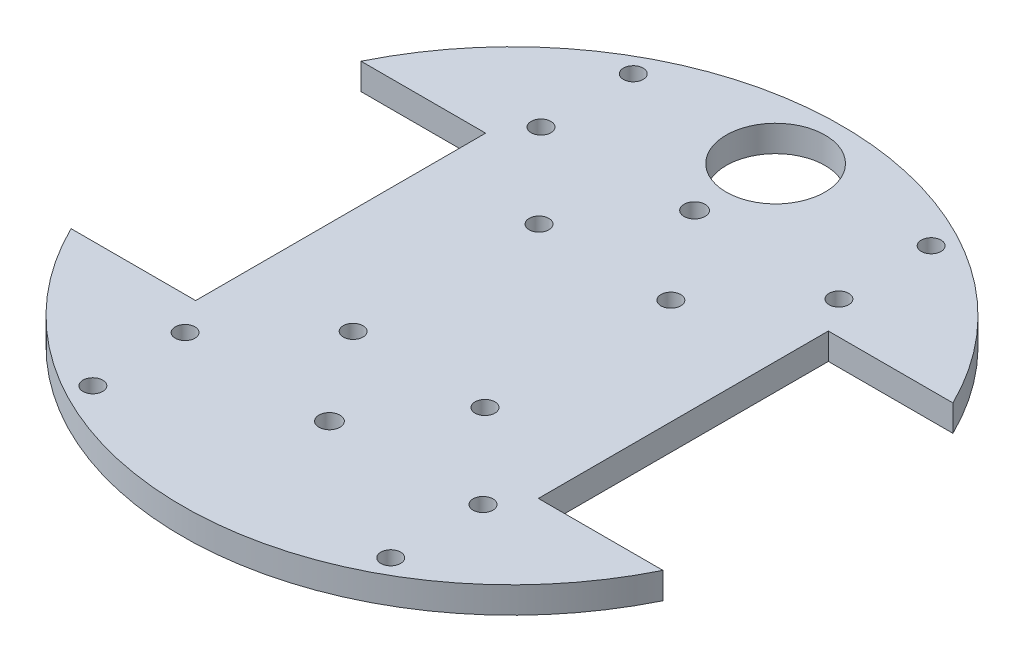
from build123d import *

# Parameters (mm, degrees)
SKETCH1_R           = 1.5
SKETCH1_R_2         = 1.6
SKETCH1_R_3         = 7.5
BOSS_EXTRUDE1_DEPTH = 4


with BuildPart() as part:
    # Sketch1 → Boss-Extrude1 (new body)
    with BuildSketch(Plane(origin=(0, 0, 0), x_dir=(1, 0, 0), z_dir=(0, 1, 0))):
        with BuildLine():
            Line((-44.899888641, 22), (-26, 22))
            Line((-26, 22), (-26, -22))
            Line((-26, -22), (-44.899888641, -22))
            ThreePointArc((-44.899888641, -22), (0, -50), (44.899888641, -22))
            Line((44.899888641, -22), (26, -22))
            Line((26, -22), (26, 22))
            Line((26, 22), (44.899888641, 22))
            ThreePointArc((44.899888641, 22), (0, 50), (-44.899888641, 22))
        make_face()
        with Locations((-22.6, -41)):
            Circle(SKETCH1_R, mode=Mode.SUBTRACT)
        with Locations((-22.6, -27)):
            Circle(SKETCH1_R, mode=Mode.SUBTRACT)
        with Locations((-10, -14.1)):
            Circle(SKETCH1_R, mode=Mode.SUBTRACT)
        with Locations((0, -27.7)):
            Circle(SKETCH1_R_2, mode=Mode.SUBTRACT)
        with Locations((22.6, -41)):
            Circle(SKETCH1_R, mode=Mode.SUBTRACT)
        with Locations((22.6, -27)):
            Circle(SKETCH1_R, mode=Mode.SUBTRACT)
        with Locations((10, -14.1)):
            Circle(SKETCH1_R, mode=Mode.SUBTRACT)
        with Locations((-10, 14.1)):
            Circle(SKETCH1_R, mode=Mode.SUBTRACT)
        with Locations((-22.6, 27)):
            Circle(SKETCH1_R, mode=Mode.SUBTRACT)
        with Locations((-22.6, 41)):
            Circle(SKETCH1_R, mode=Mode.SUBTRACT)
        with Locations((0, 40)):
            Circle(SKETCH1_R_3, mode=Mode.SUBTRACT)
        with Locations((10, 14.1)):
            Circle(SKETCH1_R, mode=Mode.SUBTRACT)
        with Locations((0, 27.7)):
            Circle(SKETCH1_R_2, mode=Mode.SUBTRACT)
        with Locations((22.6, 27)):
            Circle(SKETCH1_R, mode=Mode.SUBTRACT)
        with Locations((22.6, 41)):
            Circle(SKETCH1_R, mode=Mode.SUBTRACT)
    extrude(amount=BOSS_EXTRUDE1_DEPTH)


solid = part.part
